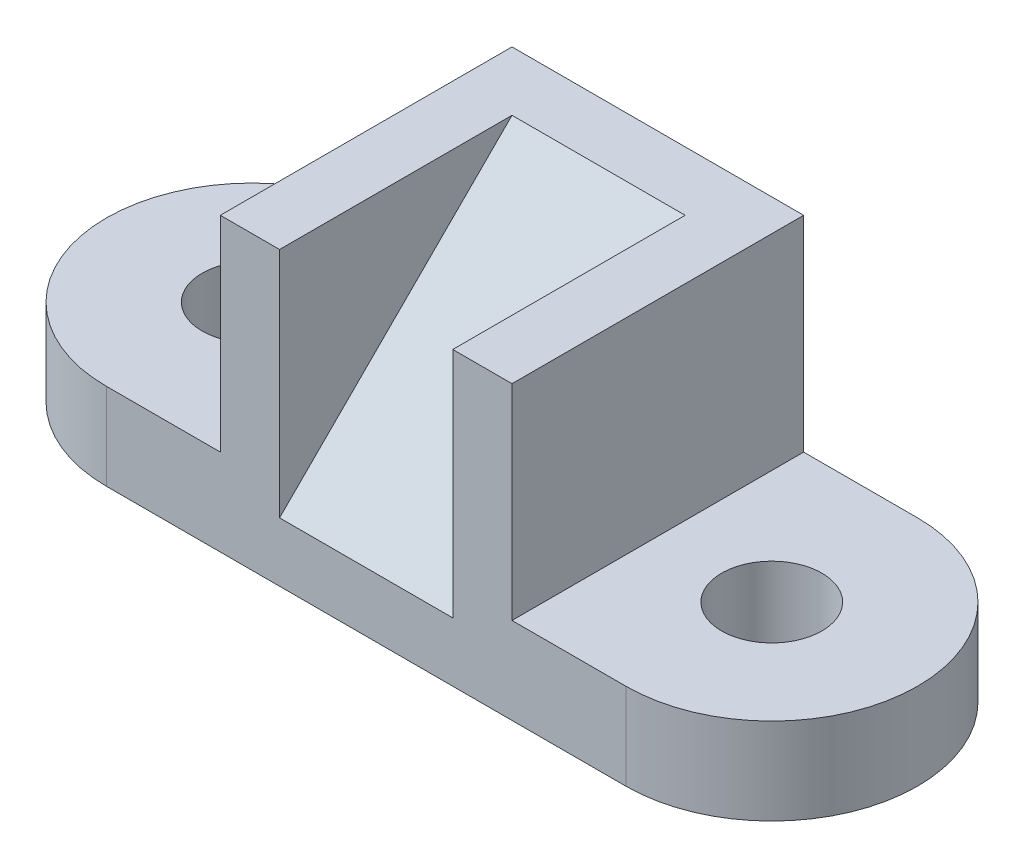
from build123d import *

# Parameters (mm, degrees)
SKETCH1_R             = 11
BOSS_EXTRUDE1_DEPTH   = 19
BOSS_EXTRUDE1_2_DEPTH = 19
BOSS_EXTRUDE2_DEPTH   = 64
SKETCH1_4_W           = 38
SKETCH1_4_H           = 51
BOSS_EXTRUDE3_DEPTH   = 13
BOSS_EXTRUDE4_REACH   = 131.553


with BuildPart() as part:
    # Sketch1 → Boss-Extrude1 (new body)
    with BuildSketch(Plane(origin=(0, 0, 0), x_dir=(1, 0, 0), z_dir=(0, 1, 0))):
        with BuildLine():
            Line((25, 32), (0, 32))
            ThreePointArc((0, 32), (-32, 0), (0, -32))
            Line((0, -32), (25, -32))
            Line((25, -32), (25, 32))
        make_face()
        Circle(SKETCH1_R, mode=Mode.SUBTRACT)
    extrude(amount=BOSS_EXTRUDE1_DEPTH)



with BuildPart() as body_2:
    # Sketch1 → Boss-Extrude1 2 (new body)
    with BuildSketch(Plane(origin=(0, 0, 0), x_dir=(1, 0, 0), z_dir=(0, 1, 0))):
        with BuildLine():
            Line((114, 32), (89, 32))
            Line((89, 32), (89, -32))
            Line((89, -32), (114, -32))
            ThreePointArc((114, -32), (146, 0), (114, 32))
        make_face()
        with Locations((114, 0)):
            Circle(SKETCH1_R, mode=Mode.SUBTRACT)
    extrude(amount=BOSS_EXTRUDE1_2_DEPTH)


with BuildPart() as part_1:
    add(part.part)

    add(body_2.part)  # Boss-Extrude2 merges body 2
    # Sketch1_3 → Boss-Extrude2 (add)
    with BuildSketch(Plane(origin=(0, 0, 0), x_dir=(1, 0, 0), z_dir=(0, 1, 0))):
        Polygon((89, 32), (25, 32), (25, -32), (38, -32), (38, 19), (76, 19), (76, -32), (89, -32), align=None)
    extrude(amount=BOSS_EXTRUDE2_DEPTH)

    # Sketch1_4 → Boss-Extrude3 (add)
    with BuildSketch(Plane(origin=(0, 0, 0), x_dir=(1, 0, 0), z_dir=(0, 1, 0))):
        with Locations((57, -6.5)):
            Rectangle(SKETCH1_4_W, SKETCH1_4_H)
    extrude(amount=BOSS_EXTRUDE3_DEPTH)

    # Sketch3 → Boss-Extrude4 (add, up to next)
    with BuildSketch(Plane(origin=(38, 0, 0), x_dir=(0, 0, -1), z_dir=(1, 0, 0)), mode=Mode.PRIVATE) as boss_extrude4_sk1:
        Polygon((19, 64), (-32, 13), (19, 13), align=None)
    boss_extrude4_tool1 = extrude(boss_extrude4_sk1.sketch, amount=BOSS_EXTRUDE4_REACH, mode=Mode.PRIVATE) - part_1.part
    add(boss_extrude4_tool1.solids().sort_by_distance((38, 30, -2))[0])


solid = part_1.part
